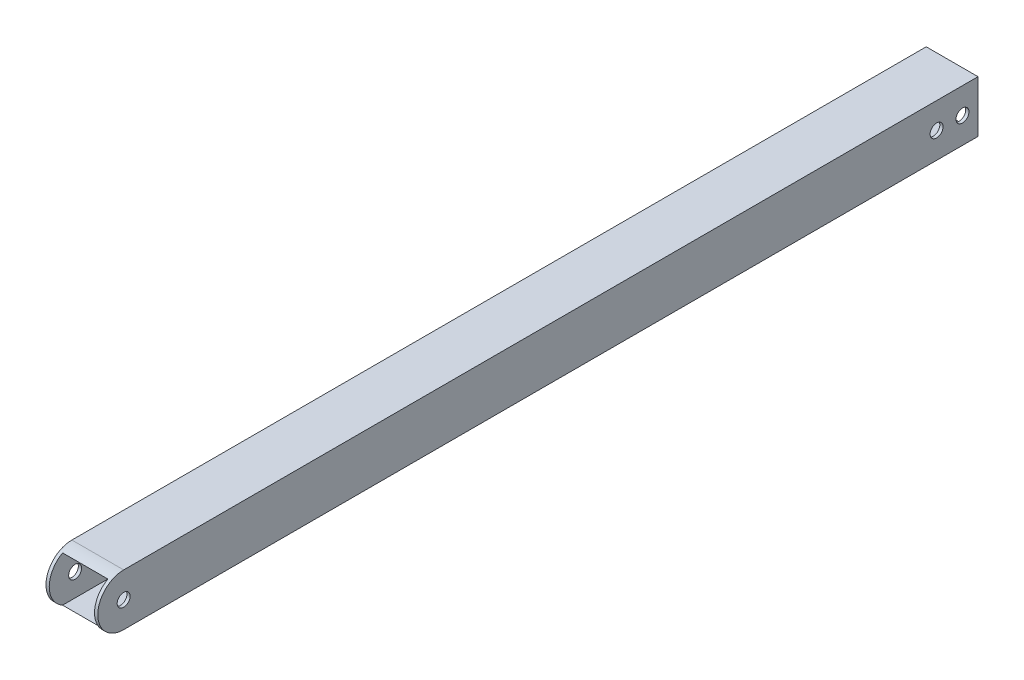
from build123d import *

# Parameters (mm, degrees)
SKETCH1_W           = 25.4
SKETCH1_H           = 25.4
SKETCH1_W_2         = 22.225
SKETCH1_H_2         = 22.225
BOSS_EXTRUDE1_DEPTH = 431.8
SKETCH2_R           = 3.175
CUT_EXTRUDE1_DEPTH  = 26.4
CUT_EXTRUDE2_DEPTH  = 491.49


with BuildPart() as part:
    # Sketch1 → Boss-Extrude1 (new body)
    with BuildSketch(Plane.XY):
        Rectangle(SKETCH1_W, SKETCH1_H)
        Rectangle(SKETCH1_W_2, SKETCH1_H_2, mode=Mode.SUBTRACT)
    extrude(amount=BOSS_EXTRUDE1_DEPTH)

    # Sketch2 → Cut-Extrude1 (cut, through all)
    with BuildSketch(Plane(origin=(12.7, 0, 0), x_dir=(0, 0, -1), z_dir=(1, 0, 0))):
        with Locations((-419.1, 0)):
            Circle(SKETCH2_R)
        with Locations((-7.62, 0)):
            Circle(SKETCH2_R)
        with Locations((-20.32, 0)):
            Circle(SKETCH2_R)
    extrude(amount=-CUT_EXTRUDE1_DEPTH, mode=Mode.SUBTRACT)

    # Sketch4 → Cut-Extrude2 (cut)
    with BuildSketch(Plane(origin=(12.7, 0, 0), x_dir=(0, 0, -1), z_dir=(1, 0, 0))):
        with BuildLine():
            Line((-419.1, 12.7), (-431.8, 12.7))
            Line((-431.8, 12.7), (-491.49, -12.7))
            Line((-491.49, -12.7), (-419.1, -12.7))
            ThreePointArc((-419.1, -12.7), (-431.8, 0), (-419.1, 12.7))
        make_face()
    extrude(amount=-CUT_EXTRUDE2_DEPTH, mode=Mode.SUBTRACT)


solid = part.part
